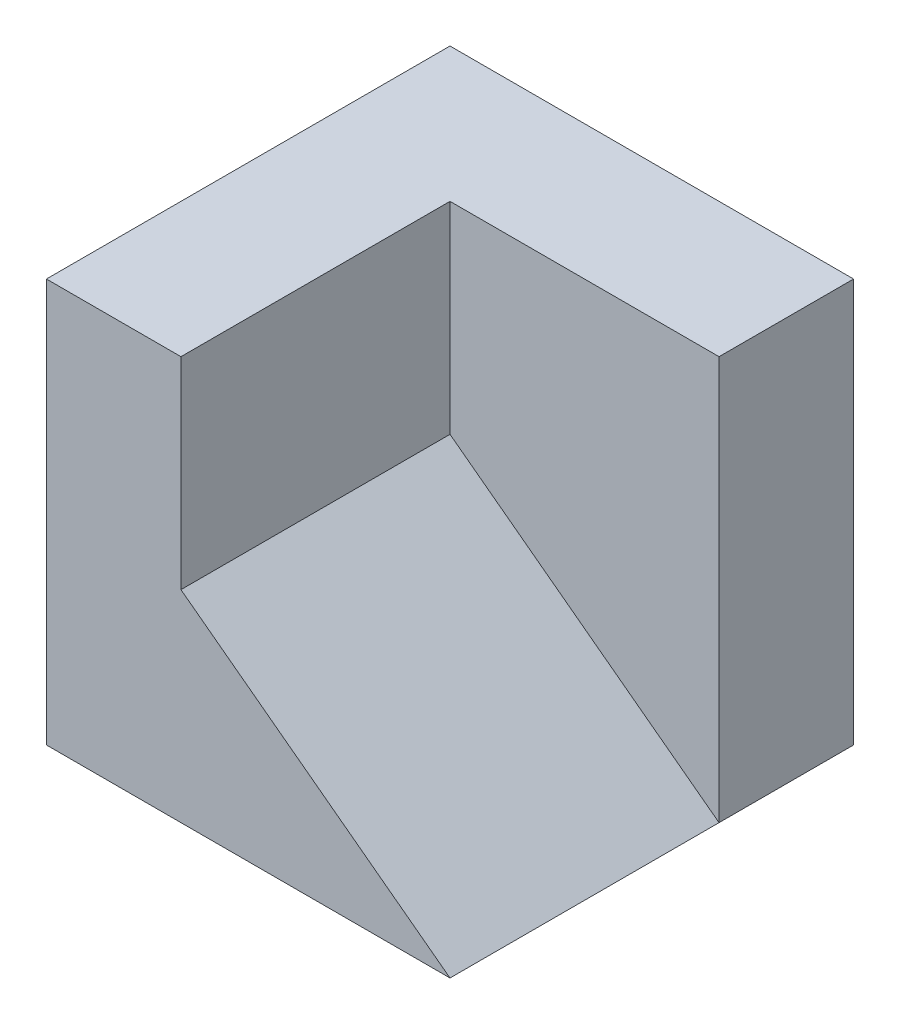
from build123d import *

# Parameters (mm, degrees)
CROQUIS2_W              = 60
CROQUIS2_H              = 60
SALIENTE_EXTRUIR1_DEPTH = 60
CORTAR_EXTRUIR1_DEPTH   = 40


with BuildPart() as part:
    # Croquis2 → Saliente-Extruir1 (new body)
    with BuildSketch(Plane(origin=(0, 0, 0), x_dir=(1, 0, 0), z_dir=(0, 1, 0))):
        with Locations((30, 30)):
            Rectangle(CROQUIS2_W, CROQUIS2_H)
    extrude(amount=SALIENTE_EXTRUIR1_DEPTH)

    # Croquis3 → Cortar-Extruir1 (cut)
    with BuildSketch(Plane.XY):
        Polygon((60, 0), (20, 30), (20, 60), (60, 60), align=None)
    extrude(amount=-CORTAR_EXTRUIR1_DEPTH, mode=Mode.SUBTRACT)


solid = part.part
